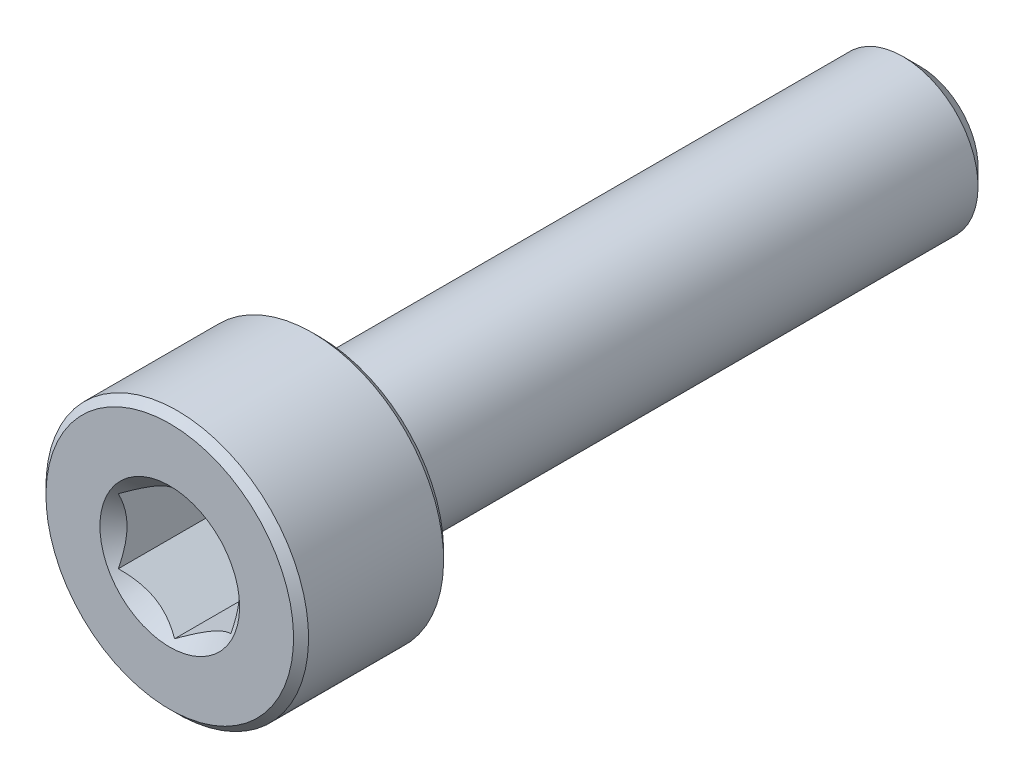
from build123d import *

# Parameters (mm, degrees)
CUT_EXTRUDE1_DEPTH = 3
SKETCH4_R          = 1.861954618
CUT_EXTRUDE2_DEPTH = 3
CUT_EXTRUDE2_DRAFT = -45


with BuildPart() as part:
    # Sketch2 → Revolve1 (revolve)
    with BuildSketch(Plane(origin=(0, 0, 0), x_dir=(0, 0, -1), z_dir=(1, 0, 0))):
        with BuildLine():
            Line((-10, 0), (-10, 3.3))
            Line((-10, 3.3), (-9.8, 3.5))
            Line((-9.8, 3.5), (-6.2, 3.5))
            Line((-6.2, 3.5), (-6, 3.3))
            Line((-6, 3.3), (-6, 2.2))
            ThreePointArc((-6, 2.2), (-5.941421356, 2.058578644), (-5.8, 2))
            Line((-5.8, 2), (9.545336663, 2))
            Line((9.545336663, 2), (10, 1.545336663))
            Line((10, 1.545336663), (10, 0))
            Line((10, 0), (-10, 0))
        make_face()
    revolve(axis=Axis((0, 0, -10), (0, 0, 1)))

    # Sketch3 → Cut-Extrude1 (cut)
    with BuildSketch(Plane.XY.offset(10)):
        Polygon((1.5, -0.866025404), (1.5, 0.866025404), (0, 1.732050808), (-1.5, 0.866025404), (-1.5, -0.866025404), (0, -1.732050808), align=None)
    extrude(amount=-CUT_EXTRUDE1_DEPTH, mode=Mode.SUBTRACT)


with BuildPart() as cut_extrude2_tool:
    # Sketch4 → Cut-Extrude2 (with draft: the straight prism first)
    with BuildSketch(Plane.XY.offset(10)):
        Circle(SKETCH4_R)
    extrude(amount=-CUT_EXTRUDE2_DEPTH)
    # Cut-Extrude2: the draft: its side faces are tilted about the plane it starts from
    cut_extrude2_sides = [cut_extrude2_tool.faces().sort_by_distance(p)[0] for p in [
        (-1.861954618, 0, 8.5),
    ]]
    draft(cut_extrude2_sides, Plane.XY.offset(10), CUT_EXTRUDE2_DRAFT)


with BuildPart() as part_1:
    add(part.part)

    # Cut-Extrude2: cut by cut_extrude2_tool
    add(cut_extrude2_tool.part, mode=Mode.SUBTRACT)


solid = part_1.part
